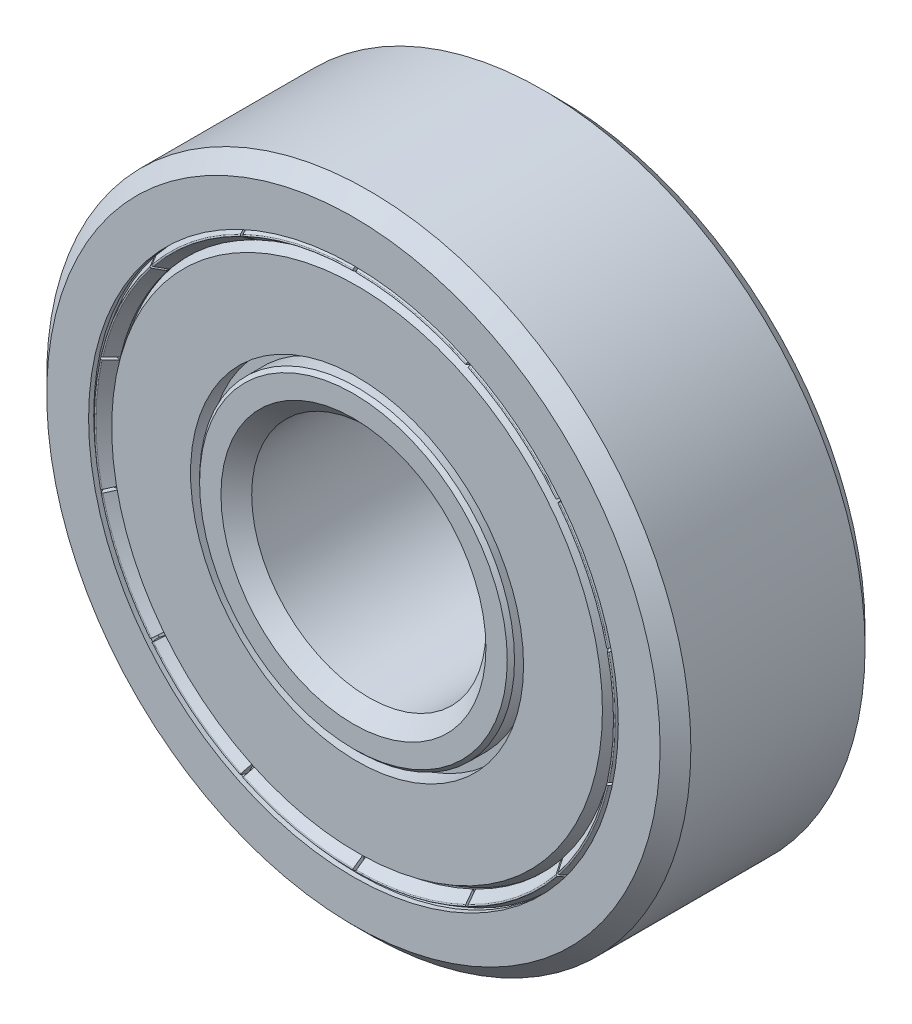
from build123d import *

# Parameters (mm, degrees)
CIRPATTERN1_COUNT  = 7
FILLET1_R          = 0.035
CUT_EXTRUDE1_START = 3.094142
CUT_EXTRUDE1_DEPTH = 1.405858
CIRPATTERN2_COUNT  = 14


with BuildPart() as part:
    # Sketch3 → Revolve1 (revolve)
    with BuildSketch(Plane(origin=(0, 0, 0), x_dir=(0, 0, -1), z_dir=(1, 0, 0))):
        with BuildLine():
            Line((2.975, 11), (-2.975, 11))
            Line((-2.975, 11), (-3.5, 10.475))
            Line((-3.5, 10.475), (-3.5, 9.046037105))
            Line((-3.5, 9.046037105), (-3.325, 9.046037105))
            Line((-3.325, 9.046037105), (-3.325, 9.498018553))
            Line((-3.325, 9.498018553), (-3.201256313, 9.621762239))
            Line((-3.201256313, 9.621762239), (-1.225, 9.621762239))
            ThreePointArc((-1.225, 9.621762239), (0, 9.95), (1.225, 9.621762239))
            Line((1.225, 9.621762239), (3.201256313, 9.621762239))
            Line((3.201256313, 9.621762239), (3.325, 9.498018553))
            Line((3.325, 9.498018553), (3.325, 9.046037105))
            Line((3.325, 9.046037105), (3.5, 9.046037105))
            Line((3.5, 9.046037105), (3.5, 10.475))
            Line((3.5, 10.475), (2.975, 11))
        make_face()
        with BuildLine():
            Line((2.975, 4), (-2.975, 4))
            Line((-2.975, 4), (-3.5, 4.525))
            Line((-3.5, 4.525), (-3.5, 5.254494074))
            Line((-3.5, 5.254494074), (-3.376256313, 5.378237761))
            Line((-3.376256313, 5.378237761), (-1.225, 5.378237761))
            ThreePointArc((-1.225, 5.378237761), (0, 5.05), (1.225, 5.378237761))
            Line((1.225, 5.378237761), (3.376256313, 5.378237761))
            Line((3.376256313, 5.378237761), (3.5, 5.254494074))
            Line((3.5, 5.254494074), (3.5, 4.525))
            Line((3.5, 4.525), (2.975, 4))
        make_face()
    revolve(axis=Axis((0, 0, 3.5), (0, 0, -1)))


with BuildPart() as body_2:
    # Sketch4 → Revolve2 (revolve)
    with BuildSketch(Plane(origin=(0, 0, 0), x_dir=(0, 0, -1), z_dir=(1, 0, 0))):
        with BuildLine():
            Line((0, 9.95), (0, 5.05))
            ThreePointArc((0, 5.05), (-2.45, 7.5), (0, 9.95))
        make_face()
    revolve(axis=Axis((0, 11, 0), (0, -1, 0)))


with BuildPart() as cirpattern1_1:
    # CirPattern1: pattern copy
    add(body_2.part.rotate(Axis((0, 0, 0), (0, 0, 1)), 1 * 360 / CIRPATTERN1_COUNT))


with BuildPart() as cirpattern1_2:
    # CirPattern1: pattern copy
    add(body_2.part.rotate(Axis((0, 0, 0), (0, 0, 1)), 2 * 360 / CIRPATTERN1_COUNT))


with BuildPart() as cirpattern1_3:
    # CirPattern1: pattern copy
    add(body_2.part.rotate(Axis((0, 0, 0), (0, 0, 1)), 3 * 360 / CIRPATTERN1_COUNT))


with BuildPart() as cirpattern1_4:
    # CirPattern1: pattern copy
    add(body_2.part.rotate(Axis((0, 0, 0), (0, 0, 1)), 4 * 360 / CIRPATTERN1_COUNT))


with BuildPart() as cirpattern1_5:
    # CirPattern1: pattern copy
    add(body_2.part.rotate(Axis((0, 0, 0), (0, 0, 1)), 5 * 360 / CIRPATTERN1_COUNT))


with BuildPart() as cirpattern1_6:
    # CirPattern1: pattern copy
    add(body_2.part.rotate(Axis((0, 0, 0), (0, 0, 1)), 6 * 360 / CIRPATTERN1_COUNT))


with BuildPart() as body_9:
    # Sketch5 → Revolve3 (revolve)
    with BuildSketch(Plane(origin=(0, 0, 0), x_dir=(0, 0, -1), z_dir=(1, 0, 0))):
        Polygon((-2.45, 5.378237761), (-2.758752104, 5.378237761), (-2.758752104, 5.686989865), (-3.376256313, 5.686989865), (-3.376256313, 8.380768779), (-2.758752104, 8.737285001), (-2.45, 8.737285001), align=None)
        Polygon((2.758752104, 8.737285001), (2.45, 8.737285001), (2.45, 5.378237761), (2.758752104, 5.378237761), (2.758752104, 5.686989865), (3.376256313, 5.686989865), (3.376256313, 8.380768779), align=None)
    revolve(axis=Axis((0, 0, 3.5), (0, 0, -1)))


with BuildPart() as body_10:
    # Sketch6 → Revolve4 (revolve)
    with BuildSketch(Plane(origin=(0, 0, 0), x_dir=(0, 0, -1), z_dir=(1, 0, 0))):
        Polygon((-2.994533294, 9.046037105), (-3.19375, 9.046037105), (-3.5, 8.869223585), (-3.099533294, 8.588813779), (-3.064533294, 8.588813779), (-2.994533294, 8.601156667), align=None)
    revolve(axis=Axis((0, 0, 3.5), (0, 0, -1)))

    # Fillet1
    fillet1_edges = [body_10.edges().sort_by_distance(p)[0] for p in [
        (0, -8.869223585, 3.5),
    ]]
    fillet(fillet1_edges, radius=FILLET1_R)

    # Sketch7 → Cut-Extrude1 (cut, through all)
    with BuildSketch(Plane.XY.offset(CUT_EXTRUDE1_START)):
        Polygon((-0.05, 9.046037105), (-0.05, 9.146037105), (0.05, 9.146037105), (0.05, 9.046037105), (0.05, 8.588813779), (0.05, 8.488813779), (-0.05, 8.488813779), (-0.05, 8.588813779), align=None)
    cut_extrude1 = extrude(amount=CUT_EXTRUDE1_DEPTH, mode=Mode.SUBTRACT)

    # CirPattern2: Cut-Extrude1 ×14 about axis
    cirpattern2_axis = Axis((0, 0, 3.5), (0, 0, -1))
    for i in range(1, CIRPATTERN2_COUNT):
        add(cut_extrude1.rotate(cirpattern2_axis, i * 360 / CIRPATTERN2_COUNT), mode=Mode.SUBTRACT)


with BuildPart() as body_11:
    # Mirror1: mirrored copy
    add(body_10.part.mirror(Plane.XY))


solid = Compound([part.part, body_2.part, cirpattern1_1.part, cirpattern1_2.part, cirpattern1_3.part, cirpattern1_4.part, cirpattern1_5.part, cirpattern1_6.part, body_9.part, body_10.part, body_11.part])
